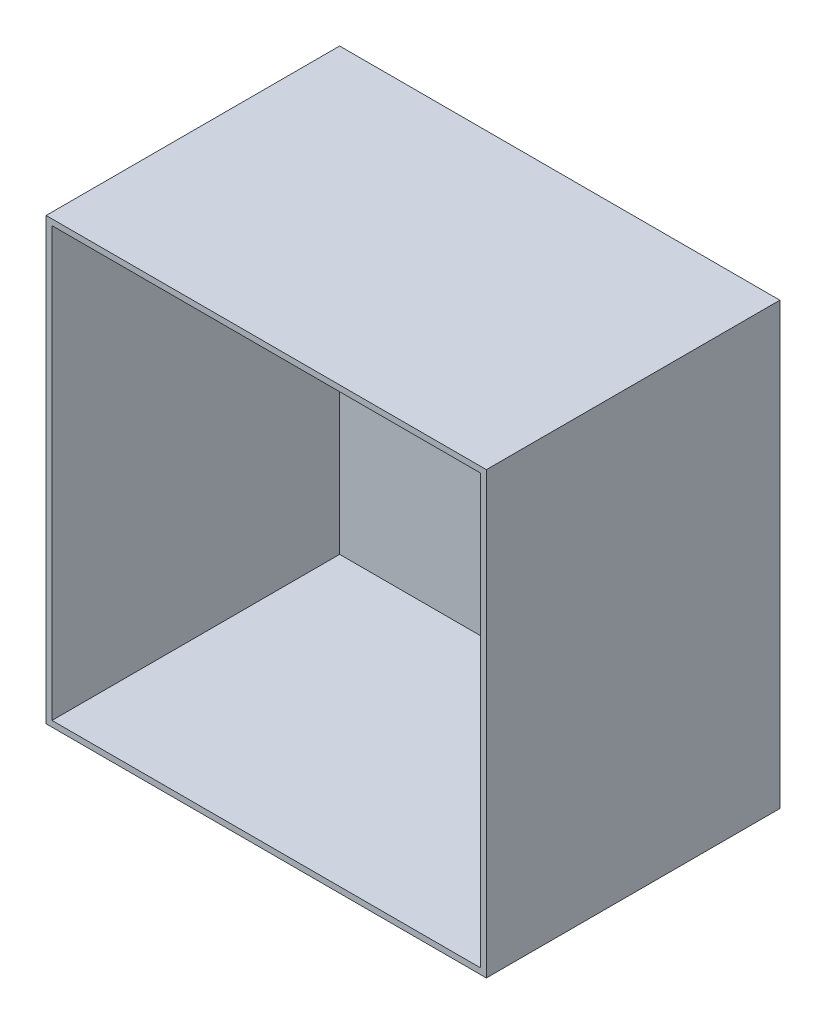
from build123d import *

# Parameters (mm, degrees)
SKETCH_1_W      = 150
SKETCH_1_H      = 150
EXTRUDE_1_DEPTH = 100
SHELL_1_T       = -2


with BuildPart() as part:
    # 草图1 → 凸台-拉伸1 (new body)
    with BuildSketch(Plane.XY):
        Rectangle(SKETCH_1_W, SKETCH_1_H)
    extrude(amount=EXTRUDE_1_DEPTH)

    # 抽壳1
    shell_1_openings = [part.faces().sort_by_distance(p)[0] for p in [
        (0, 0, 100),
    ]]
    offset(amount=SHELL_1_T, openings=shell_1_openings, kind=Kind.INTERSECTION)


solid = part.part
